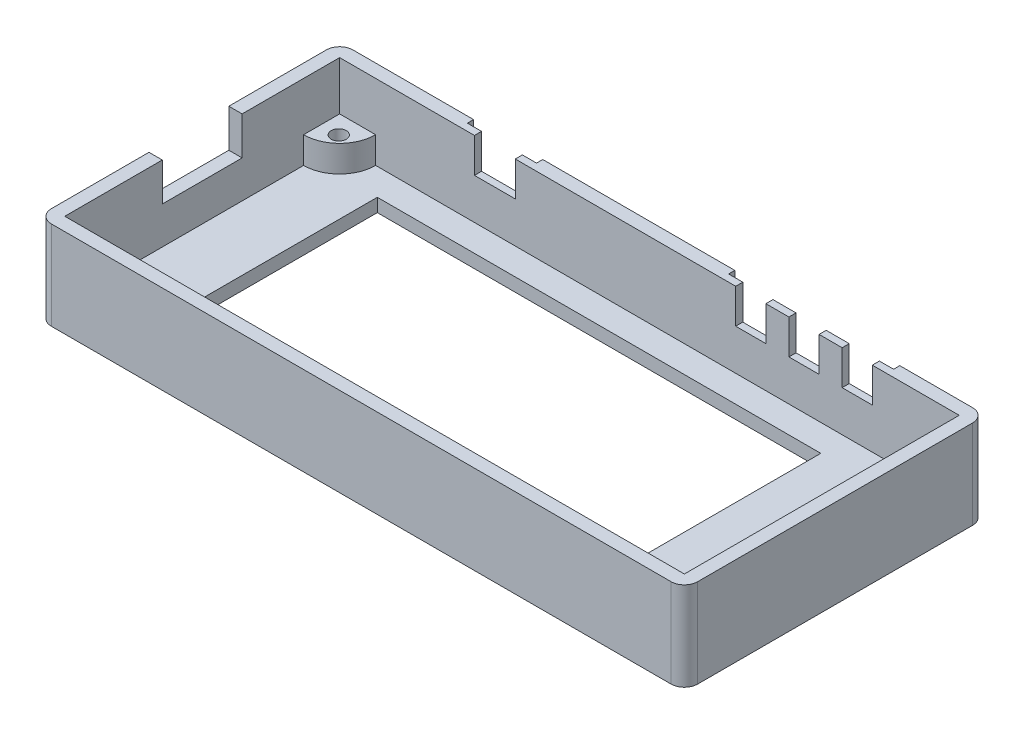
from build123d import *

# Parameters (mm, degrees)
SKETCH_1_W          = 69.855
SKETCH_1_H          = 30.988
EXTRUDE_1_DEPTH     = 1.5
CUT_EXTRUDE_2_REACH = 3.5
SKETCH_1_6_W        = 50
SKETCH_1_6_H        = 24.956
SKETCH_1_7_W        = 72.855
SKETCH_1_7_H        = 33.988
SKETCH_1_7_W_2      = 69.855
SKETCH_1_7_H_2      = 30.988
EXTRUDE_1_2_DEPTH   = 10
FILLET_1_R          = 1.5
EXTRUDE_2_DEPTH     = 3
CUT_EXTRUDE_3_REACH = 3.5
SKETCH_4_W          = 9
SKETCH_4_H          = 4.3
CUT_EXTRUDE_4_REACH = 3.5
SKETCH_5_W          = 3.4
SKETCH_5_H          = 4
SKETCH_5_W_2        = 4.6
CUT_EXTRUDE_START   = -1.5
SKETCH_5_6_W        = 7.8
SKETCH_5_6_H        = 7.2
SKETCH_5_6_W_2      = 18.6
CUT_EXTRUDE_6_DEPTH = 0.7
SKETCH_3_R          = 0.85
CUT_EXTRUDE_7_DEPTH = 3


with BuildPart() as part:
    # 草图1 → Extrude 1 (new body)
    with BuildSketch(Plane(origin=(0, 0, 0), x_dir=(1, 0, 0), z_dir=(0, 1, 0))):
        Rectangle(SKETCH_1_W, SKETCH_1_H)
    extrude(amount=EXTRUDE_1_DEPTH)

    # 草图1<6> → 切除-拉伸2 (cut, up to next)
    with BuildSketch(Plane(origin=(0, 0, 0), x_dir=(1, 0, 0), z_dir=(0, 1, 0)), mode=Mode.PRIVATE) as cut_extrude_2_sk1:
        with Locations((-2.6635, 0)):
            Rectangle(SKETCH_1_6_W, SKETCH_1_6_H)
    cut_extrude_2_tool1 = extrude(cut_extrude_2_sk1.sketch, amount=CUT_EXTRUDE_2_REACH, mode=Mode.PRIVATE) & part.part
    add(cut_extrude_2_tool1.solids().sort_by_distance((-2.6635, 0, 0))[0], mode=Mode.SUBTRACT)



with BuildPart() as body_2:
    # 草图1<7> → Extrude 1 2 (new body)
    with BuildSketch(Plane(origin=(0, 0, 0), x_dir=(1, 0, 0), z_dir=(0, 1, 0))):
        Rectangle(SKETCH_1_7_W, SKETCH_1_7_H)
        Rectangle(SKETCH_1_7_W_2, SKETCH_1_7_H_2, mode=Mode.SUBTRACT)
    extrude(amount=EXTRUDE_1_2_DEPTH)

    # 圆角1
    fillet_1_edges = [body_2.edges().sort_by_distance(p)[0] for p in [
        (-36.4275, 5, -16.994),
        (-36.4275, 5, 16.994),
        (36.4275, 5, 16.994),
        (36.4275, 5, -16.994),
    ]]
    fillet(fillet_1_edges, radius=FILLET_1_R)


with BuildPart() as part_1:
    add(part.part)

    add(body_2.part)  # 凸台-拉伸2 merges body 2
    # 草图2 → 凸台-拉伸2 (add)
    with BuildSketch(Plane(origin=(0, 1.5, 0), x_dir=(1, 0, 0), z_dir=(0, 1, 0))):
        with BuildLine():
            ThreePointArc((-30.8635, -15.494), (-32.053818041, -12.620318041), (-34.9275, -11.43))
            Line((-34.9275, -11.43), (-34.9275, -15.494))
            Line((-34.9275, -15.494), (-30.8635, -15.494))
        make_face()
        with BuildLine():
            ThreePointArc((-34.9275, 11.43), (-32.053818041, 12.620318041), (-30.8635, 15.494))
            Line((-30.8635, 15.494), (-34.9275, 15.494))
            Line((-34.9275, 15.494), (-34.9275, 11.43))
        make_face()
        with BuildLine():
            Line((34.9275, 15.494), (29.8635, 15.494))
            ThreePointArc((29.8635, 15.494), (31.34671126, 11.91321126), (34.9275, 10.43))
            Line((34.9275, 10.43), (34.9275, 15.494))
        make_face()
        with BuildLine():
            Line((34.9275, -15.494), (34.9275, -10.43))
            ThreePointArc((34.9275, -10.43), (31.34671126, -11.91321126), (29.8635, -15.494))
            Line((29.8635, -15.494), (34.9275, -15.494))
        make_face()
    extrude(amount=EXTRUDE_2_DEPTH)

    # 草图4 → 切除-拉伸3 (cut, up to next)
    with BuildSketch(Plane(origin=(-34.9275, 0, 0), x_dir=(0, 0, -1), z_dir=(1, 0, 0)), mode=Mode.PRIVATE) as cut_extrude_3_sk1:
        with Locations((0, 7.85)):
            Rectangle(SKETCH_4_W, SKETCH_4_H)
    cut_extrude_3_tool1 = extrude(cut_extrude_3_sk1.sketch, amount=-CUT_EXTRUDE_3_REACH, mode=Mode.PRIVATE) & part_1.part
    add(cut_extrude_3_tool1.solids().sort_by_distance((-34.9275, 7.85, 0))[0], mode=Mode.SUBTRACT)

    # 草图5 → 切除-拉伸4 (cut, up to next)
    with BuildSketch(Plane.XY.offset(-15.494), mode=Mode.PRIVATE) as cut_extrude_4_sk1:
        with Locations((11.4275, 8.1)):
            Rectangle(SKETCH_5_W, SKETCH_5_H)
    cut_extrude_4_tool1 = extrude(cut_extrude_4_sk1.sketch, amount=-CUT_EXTRUDE_4_REACH, mode=Mode.PRIVATE) & part_1.part
    add(cut_extrude_4_tool1.solids().sort_by_distance((11.4275, 8.1, -15.494))[0], mode=Mode.SUBTRACT)
    # 草图5 → 切除-拉伸4 (cut, up to next)
    with BuildSketch(Plane.XY.offset(-15.494), mode=Mode.PRIVATE) as cut_extrude_4_sk2:
        with Locations((17.4275, 8.1)):
            Rectangle(SKETCH_5_W, SKETCH_5_H)
    cut_extrude_4_tool2 = extrude(cut_extrude_4_sk2.sketch, amount=-CUT_EXTRUDE_4_REACH, mode=Mode.PRIVATE) & part_1.part
    add(cut_extrude_4_tool2.solids().sort_by_distance((17.4275, 8.1, -15.494))[0], mode=Mode.SUBTRACT)
    # 草图5 → 切除-拉伸4 (cut, up to next)
    with BuildSketch(Plane.XY.offset(-15.494), mode=Mode.PRIVATE) as cut_extrude_4_sk3:
        with Locations((23.4275, 8.1)):
            Rectangle(SKETCH_5_W, SKETCH_5_H)
    cut_extrude_4_tool3 = extrude(cut_extrude_4_sk3.sketch, amount=-CUT_EXTRUDE_4_REACH, mode=Mode.PRIVATE) & part_1.part
    add(cut_extrude_4_tool3.solids().sort_by_distance((23.4275, 8.1, -15.494))[0], mode=Mode.SUBTRACT)
    # 草图5 → 切除-拉伸4 (cut, up to next)
    with BuildSketch(Plane.XY.offset(-15.494), mode=Mode.PRIVATE) as cut_extrude_4_sk4:
        with Locations((-17.4275, 8.1)):
            Rectangle(SKETCH_5_W_2, SKETCH_5_H)
    cut_extrude_4_tool4 = extrude(cut_extrude_4_sk4.sketch, amount=-CUT_EXTRUDE_4_REACH, mode=Mode.PRIVATE) & part_1.part
    add(cut_extrude_4_tool4.solids().sort_by_distance((-17.4275, 8.1, -15.494))[0], mode=Mode.SUBTRACT)

    # 草图5<6> → 切除-拉伸6 (cut)
    with BuildSketch(Plane.XY.offset(-15.494).offset(CUT_EXTRUDE_START)):
        with Locations((-17.4275, 8.1)):
            Rectangle(SKETCH_5_6_W, SKETCH_5_6_H)
        with Locations((17.4275, 8.1)):
            Rectangle(SKETCH_5_6_W_2, SKETCH_5_6_H)
    extrude(amount=CUT_EXTRUDE_6_DEPTH, mode=Mode.SUBTRACT)

    # 草图3 → 切除-拉伸7 (cut)
    with BuildSketch(Plane(origin=(0, 4.5, 0), x_dir=(1, 0, 0), z_dir=(0, 1, 0))):
        with Locations((-32.9275, -13.394)):
            Circle(SKETCH_3_R)
        with Locations((-32.9275, 13.394)):
            Circle(SKETCH_3_R)
        with Locations((31.9275, -13.394)):
            Circle(SKETCH_3_R)
        with Locations((31.9275, 13.394)):
            Circle(SKETCH_3_R)
    extrude(amount=-CUT_EXTRUDE_7_DEPTH, mode=Mode.SUBTRACT)


solid = part_1.part
